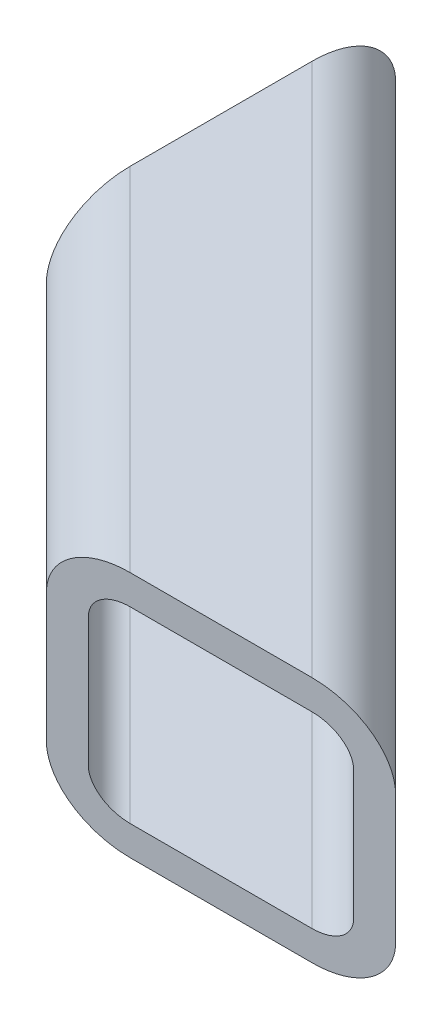
from build123d import *

# Parameters (mm, degrees)
SQ_RECT_TUBING_WELDMENT_PROFILES_SQ_TUBE_DEPTH = 89.802561211
CUT_EXTRUDE1_REACH                             = 107.603


with BuildPart() as part:
    # Sketch121 → Sq_rect_tubing_weldment_profiles SQ TUBE 1 X 1 X .120 WALL(1) (new body)
    with BuildSketch(Plane(origin=(0, 0, 0), x_dir=(0.7071067811865487, 8.862608652922434e-13, -0.7071067811865464), z_dir=(0.7071067811865464, -2.139623000789053e-12, 0.7071067811865487))):
        with BuildLine():
            Line((-6.604, -12.7), (6.604, -12.7))
            ThreePointArc((6.604, -12.7), (10.914522938, -10.914522938), (12.7, -6.604))
            Line((12.7, -6.604), (12.7, 6.604))
            ThreePointArc((12.7, 6.604), (10.914522938, 10.914522938), (6.604, 12.7))
            Line((6.604, 12.7), (-6.604, 12.7))
            ThreePointArc((-6.604, 12.7), (-10.914522938, 10.914522938), (-12.7, 6.604))
            Line((-12.7, 6.604), (-12.7, -6.604))
            ThreePointArc((-12.7, -6.604), (-10.914522938, -10.914522938), (-6.604, -12.7))
        make_face()
        with BuildLine():
            Line((-6.604, -9.652), (6.604, -9.652))
            ThreePointArc((6.604, -9.652), (8.759261469, -8.759261469), (9.652, -6.604))
            Line((9.652, -6.604), (9.652, 6.604))
            ThreePointArc((9.652, 6.604), (8.759261469, 8.759261469), (6.604, 9.652))
            Line((6.604, 9.652), (-6.604, 9.652))
            ThreePointArc((-6.604, 9.652), (-8.759261469, 8.759261469), (-9.652, 6.604))
            Line((-9.652, 6.604), (-9.652, -6.604))
            ThreePointArc((-9.652, -6.604), (-8.759261469, -8.759261469), (-6.604, -9.652))
        make_face(mode=Mode.SUBTRACT)
    extrude(amount=SQ_RECT_TUBING_WELDMENT_PROFILES_SQ_TUBE_DEPTH)

    # Cut-Extrude1: up to this face of the body (flat: up to its plane)
    cut_extrude1_end = Plane(part.part.faces().sort_by_distance((31.75, -12.7, 31.75))[0])
    # Sketch122 → Cut-Extrude1 (cut, up to the picked face)
    with BuildSketch(Plane(origin=(0, 12.7, 0), x_dir=(1, 0, 0), z_dir=(8.861583310299792e-13, 1.0, 2.139725535051317e-12)), mode=Mode.PRIVATE) as cut_extrude1_sk1:
        Polygon((8.980256121, 8.980256121), (8.980256121, -26.940768363), (-8.980256121, -8.980256121), align=None)
    cut_extrude1_tool1 = split(extrude(cut_extrude1_sk1.sketch, amount=-CUT_EXTRUDE1_REACH, mode=Mode.PRIVATE), bisect_by=cut_extrude1_end, keep=Keep.BOTH, mode=Mode.PRIVATE)
    # Sketch122 → Cut-Extrude1 (cut, up to the picked face)
    with BuildSketch(Plane(origin=(0, 12.7, 0), x_dir=(1, 0, 0), z_dir=(8.861583310299792e-13, 1.0, 2.139725535051317e-12)), mode=Mode.PRIVATE) as cut_extrude1_sk2:
        Polygon((72.480256121, -54.519743879), (36.559231637, -54.519743879), (54.519743879, -72.480256121), align=None)
    cut_extrude1_tool2 = split(extrude(cut_extrude1_sk2.sketch, amount=-CUT_EXTRUDE1_REACH, mode=Mode.PRIVATE), bisect_by=cut_extrude1_end, keep=Keep.BOTH, mode=Mode.PRIVATE)
    add(cut_extrude1_tool1.solids().sort_by(Axis((2.993419, 12.7, 8.980256), (-8.861583310299792e-13, -1.0, -2.139725535051317e-12)))[0], mode=Mode.SUBTRACT)
    add(cut_extrude1_tool2.solids().sort_by(Axis((54.519744, 12.7, 60.506581), (-8.861583310299792e-13, -1.0, -2.139725535051317e-12)))[0], mode=Mode.SUBTRACT)


solid = part.part
